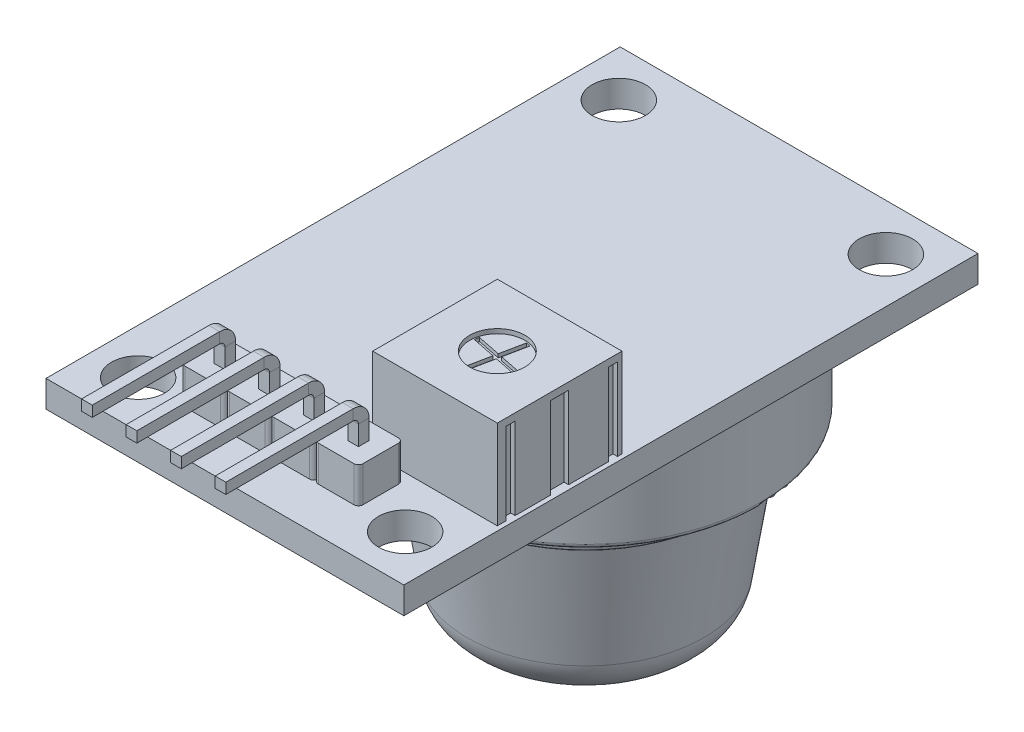
from build123d import *

# Parameters (mm, degrees)
SKETCH1_W           = 20.1
SKETCH1_H           = 32.25
SKETCH1_R           = 1.5
BOSS_EXTRUDE1_DEPTH = 1.5
SKETCH2_W           = 0.6
SKETCH2_H           = 0.6
BOSS_EXTRUDE2_DEPTH = 2
SKETCH4_W           = 0.6
SKETCH4_H           = 0.6
CUT_EXTRUDE1_DEPTH  = 1.5
SKETCH5_W           = 0.6
SKETCH5_H           = 0.6
SKETCH6_W           = 7
SKETCH6_H           = 7
BOSS_EXTRUDE3_DEPTH = 5
SKETCH7_W           = 0.5
SKETCH7_H           = 1
SKETCH7_H_2         = 0.5
CUT_EXTRUDE2_DEPTH  = 4.6
SKETCH8_R           = 1.55
CUT_EXTRUDE3_DEPTH  = 0.25
CUT_EXTRUDE4_DEPTH  = 0.2


with BuildPart() as part:
    # Sketch1 → Boss-Extrude1 (new body)
    with BuildSketch(Plane(origin=(0, 0, 0), x_dir=(1, 0, 0), z_dir=(0, 1, 0))):
        with Locations((10.05, -16.125)):
            Rectangle(SKETCH1_W, SKETCH1_H)
        with Locations((2.55, -2.625)):
            Circle(SKETCH1_R, mode=Mode.SUBTRACT)
        with Locations((17.55, -2.625)):
            Circle(SKETCH1_R, mode=Mode.SUBTRACT)
        with Locations((2.55, -29.625)):
            Circle(SKETCH1_R, mode=Mode.SUBTRACT)
        with Locations((17.55, -29.625)):
            Circle(SKETCH1_R, mode=Mode.SUBTRACT)
    extrude(amount=BOSS_EXTRUDE1_DEPTH)

    # Sketch2 → Boss-Extrude2 (add)
    with BuildSketch(Plane(origin=(0, 1.5, 0), x_dir=(1, 0, 0), z_dir=(0, 1, 0))):
        with BuildLine():
            Line((5.3, -27.25), (7.3, -27.25))
            ThreePointArc((7.3, -27.25), (7.476776695, -27.323223305), (7.55, -27.5))
            ThreePointArc((7.55, -27.5), (7.623223305, -27.323223305), (7.8, -27.25))
            Line((7.8, -27.25), (9.8, -27.25))
            ThreePointArc((9.8, -27.25), (9.976776695, -27.323223305), (10.05, -27.5))
            ThreePointArc((10.05, -27.5), (10.123223305, -27.323223305), (10.3, -27.25))
            Line((10.3, -27.25), (12.3, -27.25))
            ThreePointArc((12.3, -27.25), (12.476776695, -27.323223305), (12.55, -27.5))
            ThreePointArc((12.55, -27.5), (12.623223305, -27.323223305), (12.8, -27.25))
            Line((12.8, -27.25), (14.8, -27.25))
            ThreePointArc((14.8, -27.25), (14.976776695, -27.323223305), (15.05, -27.5))
            Line((15.05, -27.5), (15.05, -29.5))
            ThreePointArc((15.05, -29.5), (14.976776695, -29.676776695), (14.8, -29.75))
            Line((14.8, -29.75), (12.8, -29.75))
            ThreePointArc((12.8, -29.75), (12.623223305, -29.676776695), (12.55, -29.5))
            ThreePointArc((12.55, -29.5), (12.476776695, -29.676776695), (12.3, -29.75))
            Line((12.3, -29.75), (10.3, -29.75))
            ThreePointArc((10.3, -29.75), (10.123223305, -29.676776695), (10.05, -29.5))
            ThreePointArc((10.05, -29.5), (9.976776695, -29.676776695), (9.8, -29.75))
            Line((9.8, -29.75), (7.8, -29.75))
            ThreePointArc((7.8, -29.75), (7.623223305, -29.676776695), (7.55, -29.5))
            ThreePointArc((7.55, -29.5), (7.476776695, -29.676776695), (7.3, -29.75))
            Line((7.3, -29.75), (5.3, -29.75))
            ThreePointArc((5.3, -29.75), (5.123223305, -29.676776695), (5.05, -29.5))
            Line((5.05, -29.5), (5.05, -27.5))
            ThreePointArc((5.05, -27.5), (5.123223305, -27.323223305), (5.3, -27.25))
        make_face()
        with Locations((6.3, -28.5)):
            Rectangle(SKETCH2_W, SKETCH2_H, mode=Mode.SUBTRACT)
        with Locations((8.8, -28.5)):
            Rectangle(SKETCH2_W, SKETCH2_H, mode=Mode.SUBTRACT)
        with Locations((11.3, -28.5)):
            Rectangle(SKETCH2_W, SKETCH2_H, mode=Mode.SUBTRACT)
        with Locations((13.8, -28.5)):
            Rectangle(SKETCH2_W, SKETCH2_H, mode=Mode.SUBTRACT)
    extrude(amount=BOSS_EXTRUDE2_DEPTH)

    # Sketch4 → Cut-Extrude1 (cut)
    with BuildSketch(Plane(origin=(0, 1.5, 0), x_dir=(1, 0, 0), z_dir=(0, 1, 0))):
        with Locations((8.8, -28.5)):
            Rectangle(SKETCH4_W, SKETCH4_H)
        with Locations((6.3, -28.5)):
            Rectangle(SKETCH4_W, SKETCH4_H)
        with Locations((11.3, -28.5)):
            Rectangle(SKETCH4_W, SKETCH4_H)
        with Locations((13.8, -28.5)):
            Rectangle(SKETCH4_W, SKETCH4_H)
    extrude(amount=-CUT_EXTRUDE1_DEPTH, mode=Mode.SUBTRACT)

    # Sweep1: sweep along a path in Sketch3
    with BuildLine(Plane.ZY.offset(-5.05)) as sweep1_path:
        Line((28.5, -1.2), (28.5, 4.6))
        ThreePointArc((28.5, 4.6), (28.675735931, 5.024264069), (29.1, 5.2))
        Line((29.1, 5.2), (36.25, 5.2))
    # Sketch5 → Sweep1 (sweep)
    with BuildSketch(Plane(origin=(0, -1.2, 0), x_dir=(-1, 0, 0), z_dir=(0, -1, 0))):
        with Locations((-6.3, -28.5)):
            Rectangle(SKETCH5_W, SKETCH5_H)
        with Locations((-8.8, -28.5)):
            Rectangle(SKETCH5_W, SKETCH5_H)
        with Locations((-11.3, -28.5)):
            Rectangle(SKETCH5_W, SKETCH5_H)
        with Locations((-13.8, -28.5)):
            Rectangle(SKETCH5_W, SKETCH5_H)
    sweep(path=sweep1_path.line)

    # Sketch11 → Revolve1 (revolve)
    with BuildSketch(Plane(origin=(0, 0, 12), x_dir=(-1, 0, 0), z_dir=(0, 0, -1))):
        with BuildLine():
            Line((-10.05, 0), (-0.5, 0))
            ThreePointArc((-0.5, 0), (-0.323223305, -0.073223305), (-0.25, -0.25))
            Line((-0.25, -0.25), (-0.25, -4.75))
            ThreePointArc((-0.25, -4.75), (-0.323223305, -4.926776695), (-0.5, -5))
            Line((-0.5, -5), (-1.838218228, -5))
            ThreePointArc((-1.838218228, -5), (-1.999811952, -5.059245004), (-2.084816709, -5.208900253))
            Line((-2.084816709, -5.208900253), (-2.293036658, -6.458219949))
            ThreePointArc((-2.293036658, -6.458219949), (-2.31003761, -6.488150999), (-2.342356354, -6.5))
            Line((-2.342356354, -6.5), (-2.4, -6.5))
            Line((-2.4, -6.5), (-3.39310828, -12.884267516))
            ThreePointArc((-3.39310828, -12.884267516), (-4.237156665, -14.398771812), (-5.863399453, -15))
            Line((-5.863399453, -15), (-10.05, -15))
            Line((-10.05, -15), (-10.05, 0))
        make_face()
    revolve(axis=Axis((10.05, -15, 12), (0, 1, 0)))


with BuildPart() as body_2:
    # Sketch6 → Boss-Extrude3 (new body)
    with BuildSketch(Plane(origin=(0, 1.5, 0), x_dir=(1, 0, 0), z_dir=(0, 1, 0))):
        with Locations((16.35, -23.25)):
            Rectangle(SKETCH6_W, SKETCH6_H)
    extrude(amount=BOSS_EXTRUDE3_DEPTH)

    # Sketch7 → Cut-Extrude2 (cut)
    with BuildSketch(Plane.XZ.offset(-1.5)):
        with Locations((19.85, 23.25)):
            Rectangle(SKETCH7_W, SKETCH7_H)
        with Locations((19.85, 26)):
            Rectangle(SKETCH7_W, SKETCH7_H_2)
        with Locations((19.85, 20.25)):
            Rectangle(SKETCH7_W, SKETCH7_H_2)
    extrude(amount=-CUT_EXTRUDE2_DEPTH, mode=Mode.SUBTRACT)

    # Sketch8 → Cut-Extrude3 (cut)
    with BuildSketch(Plane(origin=(0, 6.5, 0), x_dir=(1, 0, 0), z_dir=(0, 1, 0))):
        with Locations((16.35, -23.25)):
            Circle(SKETCH8_R)
    extrude(amount=-CUT_EXTRUDE3_DEPTH, mode=Mode.SUBTRACT)

    # Sketch9 → Cut-Extrude4 (cut)
    with BuildSketch(Plane(origin=(0, 6.25, 0), x_dir=(1, 0, 0), z_dir=(0, 1, 0))):
        with BuildLine():
            Line((16.52061089, -21.787346857), (16.25248865, -23.102549884))
            Line((16.25248865, -23.102549884), (14.937285624, -22.834427645))
            ThreePointArc((14.937285624, -22.834427645), (14.907108416, -22.955846691), (14.887346857, -23.07938911))
            Line((14.887346857, -23.07938911), (16.202549884, -23.34751135))
            Line((16.202549884, -23.34751135), (15.934427645, -24.662714376))
            ThreePointArc((15.934427645, -24.662714376), (16.055846691, -24.692891584), (16.17938911, -24.712653143))
            Line((16.17938911, -24.712653143), (16.44751135, -23.397450116))
            Line((16.44751135, -23.397450116), (17.762714376, -23.665572355))
            ThreePointArc((17.762714376, -23.665572355), (17.792891584, -23.544153309), (17.812653143, -23.42061089))
            Line((17.812653143, -23.42061089), (16.497450116, -23.15248865))
            Line((16.497450116, -23.15248865), (16.765572355, -21.837285624))
            ThreePointArc((16.765572355, -21.837285624), (16.644153309, -21.807108416), (16.52061089, -21.787346857))
        make_face()
    extrude(amount=-CUT_EXTRUDE4_DEPTH, mode=Mode.SUBTRACT)


solid = Compound([part.part, body_2.part])
